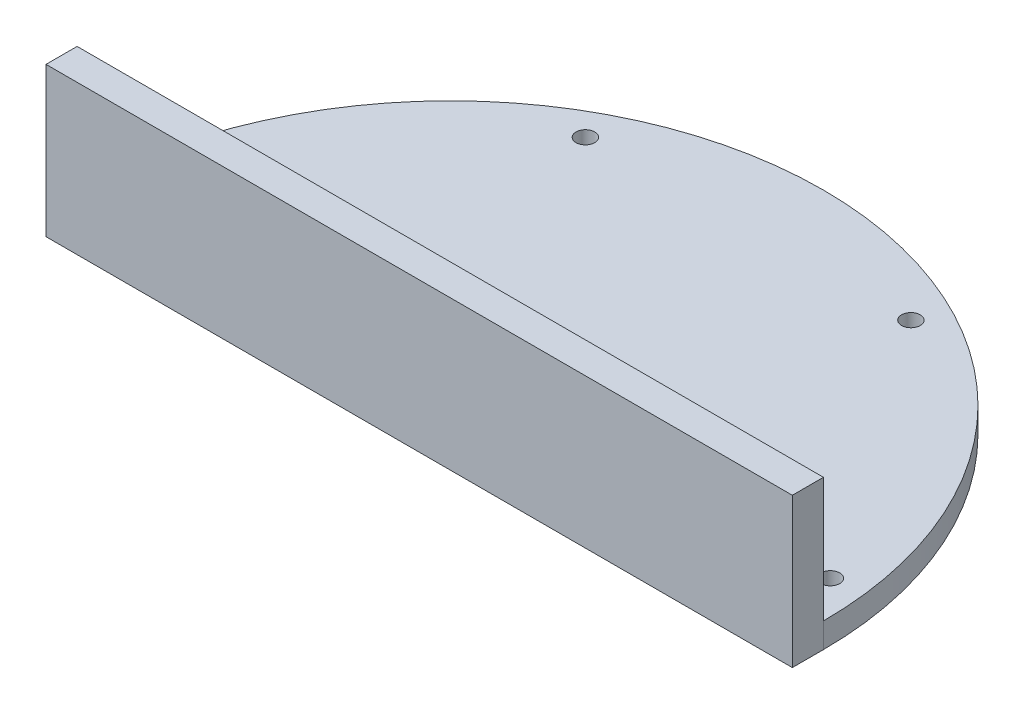
from build123d import *

# Parameters (mm, degrees)
BOSS_EXTRUDE1_DEPTH     = 5
SKETCH2_R               = 1.5
CUT_EXTRUDE1_DEPTH      = 5
CIRPATTERN1_COUNT       = 4
CIRPATTERN1_ANGLE       = 168
SKETCH9_W               = 120
SKETCH9_H               = 25
BOSS_EXTRUDE5_DEPTH     = 5
MIRROR3_COPY_1_SKETCH_R = 1.5
MIRROR3_COPY_1_DEPTH    = 5
MIRROR3_COPY_2_SKETCH_R = 1.5
MIRROR3_COPY_2_DEPTH    = 5
MIRROR3_COPY_3_SKETCH_R = 1.5
MIRROR3_COPY_3_DEPTH    = 5
SKETCH11_W              = 83.519878
SKETCH11_H              = 28.939674
CUT_EXTRUDE2_DEPTH      = 150
CHAMFER1_SIZE           = 1


with BuildPart() as part:
    # Sketch1 → Boss-Extrude1 (new body)
    with BuildSketch(Plane(origin=(0, 0, 0), x_dir=(1, 0, 0), z_dir=(0, 1, 0))):
        with BuildLine():
            Line((-60, 0), (-25.75, 0))
            Line((-25.75, 0), (25.75, 0))
            Line((25.75, 0), (60, 0))
            ThreePointArc((60, 0), (0, 60), (-60, 0))
        make_face()
    boss_extrude1 = extrude(amount=BOSS_EXTRUDE1_DEPTH)

    # Sketch2 → Cut-Extrude1 (cut)
    with BuildSketch(Plane(origin=(0, 5, 0), x_dir=(1, 0, 0), z_dir=(0, 1, 0))):
        with Locations((-54.772256, 5)):
            Circle(SKETCH2_R)
    cut_extrude1 = extrude(amount=-CUT_EXTRUDE1_DEPTH, mode=Mode.SUBTRACT)

    # CirPattern1: Cut-Extrude1 ×4 about axis
    cirpattern1_axis = Axis((0, 0, 0), (0, -1, 0))
    for i in range(1, CIRPATTERN1_COUNT):
        add(cut_extrude1.rotate(cirpattern1_axis, i * CIRPATTERN1_ANGLE / (CIRPATTERN1_COUNT - 1)), mode=Mode.SUBTRACT)

    # Sketch9 → Boss-Extrude5 (add)
    with BuildSketch(Plane.XY):
        with Locations((0, -7.5)):
            Rectangle(SKETCH9_W, SKETCH9_H)
    boss_extrude5 = extrude(amount=BOSS_EXTRUDE5_DEPTH)

    # Mirror3: Boss-Extrude1, Cut-Extrude1, Boss-Extrude5 across plane
    add(boss_extrude1.mirror(Plane.ZX.offset(5)))
    add(cut_extrude1.mirror(Plane.ZX.offset(5)), mode=Mode.SUBTRACT)
    add(boss_extrude5.mirror(Plane.ZX.offset(5)))

    # Mirror3 copy 1 sketch → Mirror3 copy 1 (cut)
    with BuildSketch(Plane(origin=(0, 5, 0), x_dir=(0.559193, 0, 0.829038), z_dir=(0, -1, 0))):
        with Locations((-54.772256, -5)):
            Circle(MIRROR3_COPY_1_SKETCH_R)
    extrude(amount=-MIRROR3_COPY_1_DEPTH, mode=Mode.SUBTRACT)

    # Mirror3 copy 2 sketch → Mirror3 copy 2 (cut)
    with BuildSketch(Plane(origin=(0, 5, 0), x_dir=(-0.374607, 0, 0.927184), z_dir=(0, -1, 0))):
        with Locations((-54.772256, -5)):
            Circle(MIRROR3_COPY_2_SKETCH_R)
    extrude(amount=-MIRROR3_COPY_2_DEPTH, mode=Mode.SUBTRACT)

    # Mirror3 copy 3 sketch → Mirror3 copy 3 (cut)
    with BuildSketch(Plane(origin=(0, 5, 0), x_dir=(-0.978148, 0, 0.207912), z_dir=(0, -1, 0))):
        with Locations((-54.772256, -5)):
            Circle(MIRROR3_COPY_3_SKETCH_R)
    extrude(amount=-MIRROR3_COPY_3_DEPTH, mode=Mode.SUBTRACT)

    # Sketch11 → Cut-Extrude2 (cut)
    with BuildSketch(Plane.ZY.offset(60)):
        with Locations((-36.759939, -9.469837)):
            Rectangle(SKETCH11_W, SKETCH11_H)
    extrude(amount=-CUT_EXTRUDE2_DEPTH, mode=Mode.SUBTRACT)

    # Chamfer1
    chamfer1_edges = [part.edges().sort_by_distance(p)[0] for p in [
        (0, 5, 5),
        (56.08213, 5, -6.808922),
        (-27.321858, 5, -49.447779),
        (60, 5, 2.5),
        (0, 5, -60),
        (25.715877, 5, -50.301694),
        (-56.272256, 5, -5),
        (-60, 5, 2.5),
    ]]
    chamfer(chamfer1_edges, length=CHAMFER1_SIZE)


solid = part.part
